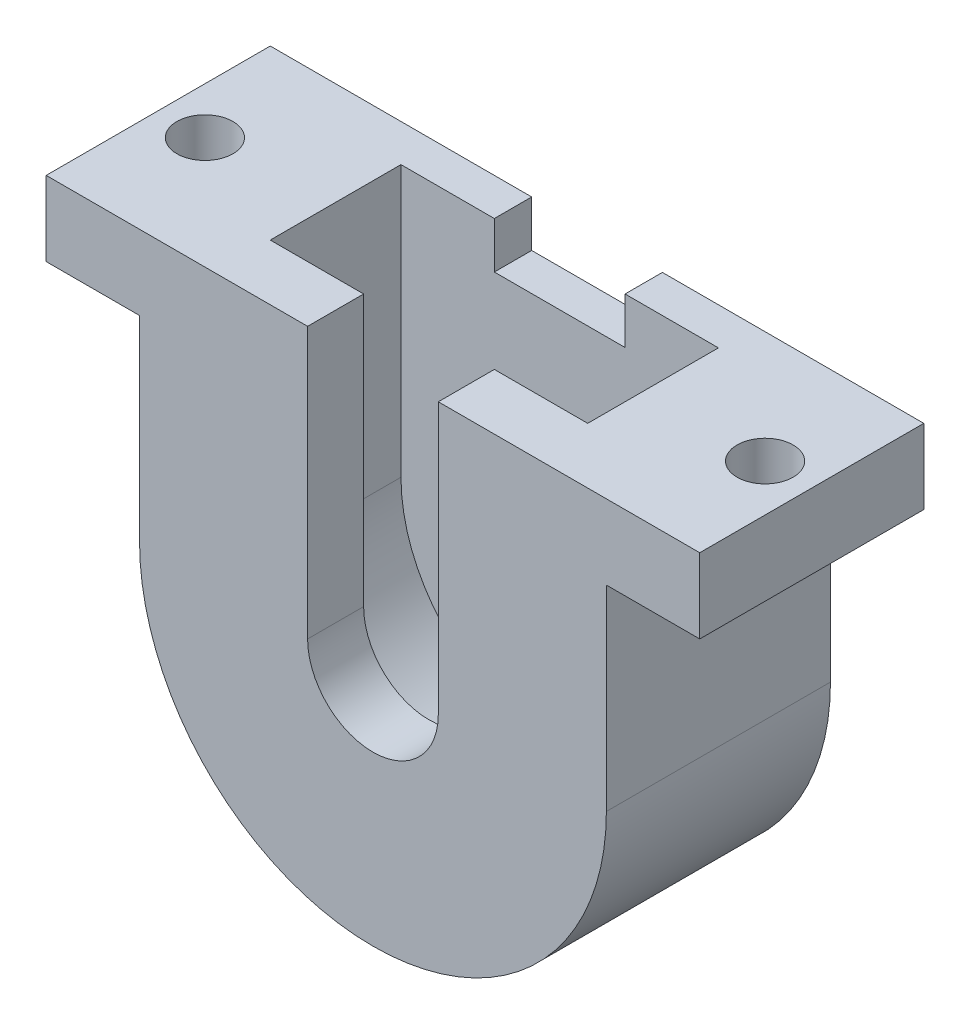
from build123d import *

# Parameters (mm, degrees)
SALIENTE_EXTRUIR1_DEPTH    = 38
SALIENTE_EXTRUIR2_DEPTH    = 3
SALIENTE_EXTRUIR3_DEPTH    = 2
CROQUIS4_R                 = 1.5
SALIENTE_EXTRUIR4_DEPTH    = 4
CROQUIS5_W                 = 35
CROQUIS5_H                 = 31
CORTAR_EXTRUIR1_DEPTH      = 24
CORTAR_EXTRUIR1_DEPTH_BACK = 5
SALIENTE_EXTRUIR5_DEPTH    = 2


with BuildPart() as part:
    # Croquis1 → Saliente-Extruir1 (new body)
    with BuildSketch(Plane.XY):
        with BuildLine():
            Line((10.5, 10.5), (12.5, 10.5))
            Line((12.5, 10.5), (12.5, 0))
            ThreePointArc((12.5, 0), (0, -12.5), (-12.5, 0))
            Line((-12.5, 0), (-12.5, 10.5))
            Line((-12.5, 10.5), (-10.5, 10.5))
            Line((-10.5, 10.5), (-8.5, 10.5))
            Line((-8.5, 10.5), (-8.5, 0))
            ThreePointArc((-8.5, 0), (0, -8.5), (8.5, 0))
            Line((8.5, 0), (8.5, 10.5))
            Line((8.5, 10.5), (10.5, 10.5))
        make_face()
    extrude(amount=SALIENTE_EXTRUIR1_DEPTH)

    # Croquis2 → Saliente-Extruir2 (add)
    with BuildSketch(Plane.XY.offset(38)):
        with BuildLine():
            Line((-12.5, 10.5), (-3.5, 10.5))
            Line((-3.5, 10.5), (-3.5, 0))
            ThreePointArc((-3.5, 0), (0, -3.5), (3.5, 0))
            Line((3.5, 0), (3.5, 10.5))
            Line((3.5, 10.5), (12.5, 10.5))
            Line((12.5, 10.5), (12.5, 0))
            ThreePointArc((12.5, 0), (0, -12.5), (-12.5, 0))
            Line((-12.5, 0), (-12.5, 10.5))
        make_face()
    extrude(amount=SALIENTE_EXTRUIR2_DEPTH)

    # Croquis3 → Saliente-Extruir3 (add)
    with BuildSketch(Plane(origin=(0, 0, 0), x_dir=(-1, 0, 0), z_dir=(0, 0, -1))):
        with BuildLine():
            Line((-12.5, 10.5), (12.5, 10.5))
            Line((12.5, 10.5), (12.5, 0))
            ThreePointArc((12.5, 0), (0, -12.5), (-12.5, 0))
            Line((-12.5, 0), (-12.5, 10.5))
        make_face()
    extrude(amount=SALIENTE_EXTRUIR3_DEPTH)

    # Croquis4 → Saliente-Extruir4 (add)
    with BuildSketch(Plane(origin=(0, 10.5, 0), x_dir=(1, 0, 0), z_dir=(0, 1, 0))):
        Polygon((17.5, -41), (3.5, -41), (3.5, -38), (8.5, -38), (8.5, -26.565627665), (17.5, -26.565627665), align=None)
        with Locations((15, -35)):
            Circle(CROQUIS4_R, mode=Mode.SUBTRACT)
        Polygon((-17.5, -41), (-17.5, -26.565627665), (-8.5, -26.565627665), (-8.5, -38), (-3.5, -38), (-3.5, -41), align=None)
        with Locations((-15, -35)):
            Circle(CROQUIS4_R, mode=Mode.SUBTRACT)
    extrude(amount=SALIENTE_EXTRUIR4_DEPTH)

    # Croquis5 → Cortar-Extruir1 (cut, two sides)
    with BuildSketch(Plane.XZ.offset(-10.5)) as cortar_extruir1_sk:
        with Locations((0, 13.5)):
            Rectangle(CROQUIS5_W, CROQUIS5_H)
    extrude(amount=CORTAR_EXTRUIR1_DEPTH, mode=Mode.SUBTRACT)
    extrude(cortar_extruir1_sk.sketch, amount=-CORTAR_EXTRUIR1_DEPTH_BACK, mode=Mode.SUBTRACT)

    # Croquis6 → Saliente-Extruir5 (add)
    with BuildSketch(Plane(origin=(0, 0, 29), x_dir=(-1, 0, 0), z_dir=(0, 0, -1))):
        with BuildLine():
            Line((-8.5, 14.5), (-3.5, 14.5))
            Line((-3.5, 14.5), (-3.5, 12.017542708))
            Line((-3.5, 12.017542708), (3.5, 12.017542708))
            Line((3.5, 12.017542708), (3.5, 14.5))
            Line((3.5, 14.5), (8.5, 14.5))
            Line((8.5, 14.5), (8.5, 0))
            ThreePointArc((8.5, 0), (0, -8.5), (-8.5, 0))
            Line((-8.5, 0), (-8.5, 14.5))
        make_face()
    extrude(amount=-SALIENTE_EXTRUIR5_DEPTH)


solid = part.part
